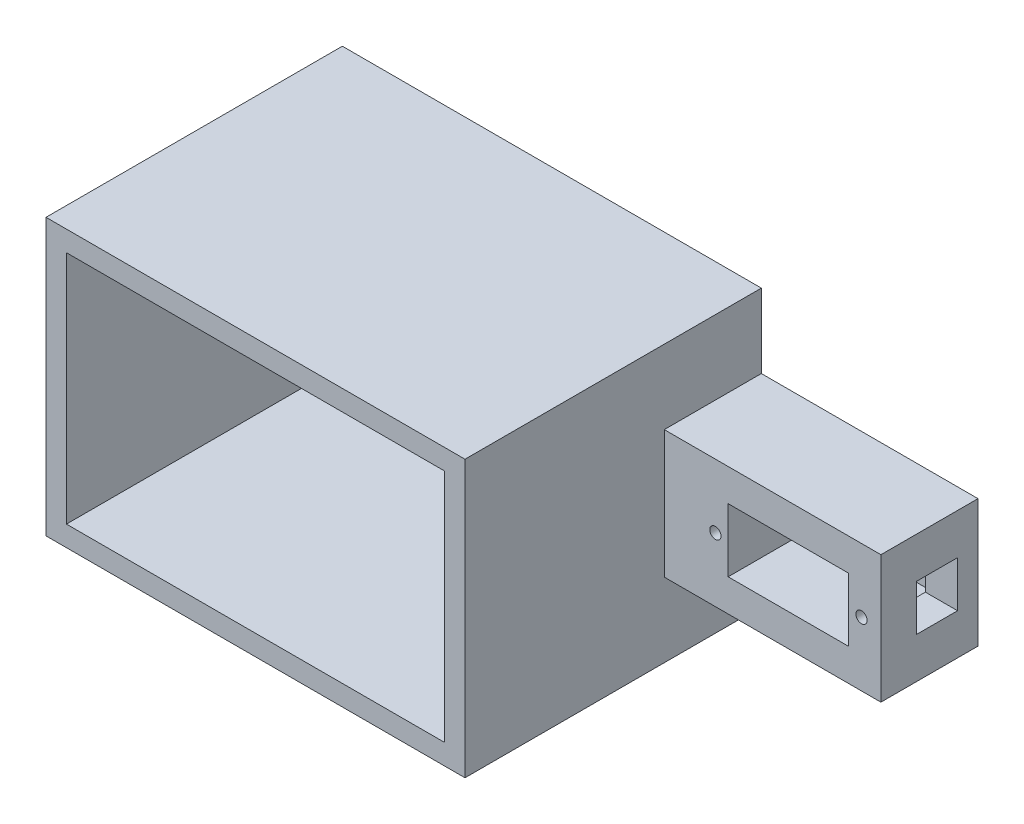
from build123d import *

# Parameters (mm, degrees)
SKETCH_1_W           = 45
SKETCH_1_H           = 25
EXTRUDE_2_DEPTH      = 19
SKETCH_4_W           = 23.6
SKETCH_4_H           = 12.4
CUT_EXTRUDE_2_DEPTH  = 17.5
SKETCH_5_W           = 8
SKETCH_5_H           = 9
CUT_EXTRUDE_4_DEPTH  = 7
SKETCH_6_R           = 1.1
CUT_EXTRUDE_6_DEPTH  = 7.5
SKETCH_8_W           = 2.6
SKETCH_8_H           = 25
EXTRUDE_3_DEPTH      = 17.5
SKETCH_10_W          = 36.5
SKETCH_10_H          = 60
EXTRUDE_5_DEPTH      = 2.6
SKETCH_13_W          = 36.5
SKETCH_13_H          = 60
EXTRUDE_6_DEPTH      = 1.4
SKETCH_14_W          = 36.5
SKETCH_14_H          = 3
CUT_EXTRUDE_9_DEPTH  = 4
SKETCH_15_W          = 36.5
SKETCH_15_H          = 3
CUT_EXTRUDE_10_DEPTH = 4
SKETCH_16_W          = 4
SKETCH_16_H          = 54
EXTRUDE_7_DEPTH      = 21.5
SKETCH_17_W          = 4
SKETCH_17_H          = 54
EXTRUDE_8_DEPTH      = 78
SKETCH_18_W          = 78
SKETCH_18_H          = 4
EXTRUDE_9_DEPTH      = 54
SKETCH_19_W          = 78
SKETCH_19_H          = 4
EXTRUDE_10_DEPTH     = 54
SKETCH_20_W          = 4
SKETCH_20_H          = 46
EXTRUDE_11_DEPTH     = 54


with BuildPart() as part:
    # 草圖1 → 填料-伸長2 (new body)
    with BuildSketch(Plane.XY):
        with Locations((-42.528991691, -4.596431101)):
            Rectangle(SKETCH_1_W, SKETCH_1_H)
    extrude(amount=EXTRUDE_2_DEPTH)

    # 草圖4 → 除料-伸長2 (cut)
    with BuildSketch(Plane.XY.offset(19)):
        with Locations((-38.128991691, -4.596431101)):
            Rectangle(SKETCH_4_W, SKETCH_4_H)
    extrude(amount=-CUT_EXTRUDE_2_DEPTH, mode=Mode.SUBTRACT)

    # 草圖5 → 除料-伸長4 (cut)
    with BuildSketch(Plane(origin=(-20.028991691, 0, 0), x_dir=(0, 0, -1), z_dir=(1, 0, 0))):
        with Locations((-8, -4.596431101)):
            Rectangle(SKETCH_5_W, SKETCH_5_H)
    extrude(amount=-CUT_EXTRUDE_4_DEPTH, mode=Mode.SUBTRACT)

    # 草圖6 → 除料-伸長6 (cut)
    with BuildSketch(Plane.XY.offset(19)):
        with Locations((-23.828991691, -4.596431101)):
            Circle(SKETCH_6_R)
        with Locations((-52.428991691, -4.596431101)):
            Circle(SKETCH_6_R)
    extrude(amount=-CUT_EXTRUDE_6_DEPTH, mode=Mode.SUBTRACT)

    # 草圖8 → 填料-伸長3 (add)
    with BuildSketch(Plane.XY.offset(19)):
        with Locations((-63.728991691, -4.596431101)):
            Rectangle(SKETCH_8_W, SKETCH_8_H)
    extrude(amount=EXTRUDE_3_DEPTH)

    # 草圖10 → 填料-伸長5 (add)
    with BuildSketch(Plane(origin=(-62.428991691, 0, 0), x_dir=(0, 0, -1), z_dir=(1, 0, 0))):
        with Locations((-18.25, -4.613155897)):
            Rectangle(SKETCH_10_W, SKETCH_10_H)
    extrude(amount=-EXTRUDE_5_DEPTH)

    # 草圖13 → 填料-伸長6 (add)
    with BuildSketch(Plane.ZY.offset(65.028991691)):
        with Locations((18.25, -4.613155897)):
            Rectangle(SKETCH_13_W, SKETCH_13_H)
    extrude(amount=EXTRUDE_6_DEPTH)

    # 草圖14 → 除料-伸長9 (cut)
    with BuildSketch(Plane(origin=(-62.428991691, 0, 0), x_dir=(0, 0, -1), z_dir=(1, 0, 0))):
        with Locations((-18.25, -33.113155897)):
            Rectangle(SKETCH_14_W, SKETCH_14_H)
    extrude(amount=-CUT_EXTRUDE_9_DEPTH, mode=Mode.SUBTRACT)

    # 草圖15 → 除料-伸長10 (cut)
    with BuildSketch(Plane(origin=(-62.428991691, 0, 0), x_dir=(0, 0, -1), z_dir=(1, 0, 0))):
        with Locations((-18.25, 23.886844103)):
            Rectangle(SKETCH_15_W, SKETCH_15_H)
    extrude(amount=-CUT_EXTRUDE_10_DEPTH, mode=Mode.SUBTRACT)

    # 草圖16 → 填料-伸長7 (add)
    with BuildSketch(Plane.XY.offset(36.5)):
        with Locations((-64.428991691, -4.613155897)):
            Rectangle(SKETCH_16_W, SKETCH_16_H)
    extrude(amount=EXTRUDE_7_DEPTH)

    # 草圖17 → 填料-伸長8 (add)
    with BuildSketch(Plane.ZY.offset(66.428991691)):
        with Locations((2, -4.613155897)):
            Rectangle(SKETCH_17_W, SKETCH_17_H)
    extrude(amount=EXTRUDE_8_DEPTH)

    # 草圖18 → 填料-伸長9 (add)
    with BuildSketch(Plane.XY.offset(4)):
        with Locations((-105.428991691, 20.386844103)):
            Rectangle(SKETCH_18_W, SKETCH_18_H)
    extrude(amount=EXTRUDE_9_DEPTH)

    # 草圖19 → 填料-伸長10 (add)
    with BuildSketch(Plane.XY.offset(4)):
        with Locations((-105.428991691, -29.613155897)):
            Rectangle(SKETCH_19_W, SKETCH_19_H)
    extrude(amount=EXTRUDE_10_DEPTH)

    # 草圖20 → 填料-伸長11 (add)
    with BuildSketch(Plane.XY.offset(4)):
        with Locations((-142.428991691, -4.613155897)):
            Rectangle(SKETCH_20_W, SKETCH_20_H)
    extrude(amount=EXTRUDE_11_DEPTH)


solid = part.part
